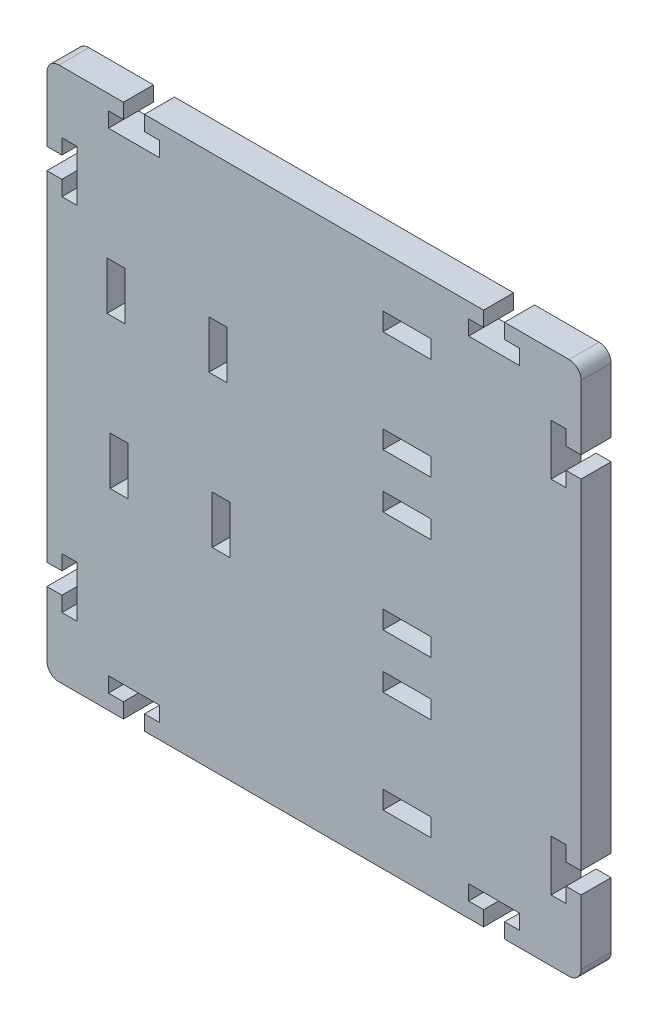
from build123d import *

# Parameters (mm, degrees)
SKETCH_1_W      = 3
SKETCH_1_H      = 8
SKETCH_1_W_2    = 8
SKETCH_1_H_2    = 3
EXTRUDE_1_DEPTH = 5


with BuildPart() as part:
    # Эскиз1 → Бобышка-Вытянуть1 (new body)
    with BuildSketch(Plane.XY):
        with BuildLine():
            Line((-31.75, 40.340066927), (-42.5, 40.340066927))
            ThreePointArc((-42.5, 40.340066927), (-43.914213562, 39.754280489), (-44.5, 38.340066927))
            Line((-44.5, 38.340066927), (-44.5, 27.590066927))
            Line((-44.5, 27.590066927), (-42, 27.590066927))
            Line((-42, 27.590066927), (-42, 30.090066927))
            Line((-42, 30.090066927), (-39.5, 30.090066927))
            Line((-39.5, 30.090066927), (-39.5, 21.590066927))
            Line((-39.5, 21.590066927), (-42, 21.590066927))
            Line((-42, 21.590066927), (-42, 24.090066927))
            Line((-42, 24.090066927), (-44.5, 24.090066927))
            Line((-44.5, 24.090066927), (-44.5, -32.409933073))
            Line((-44.5, -32.409933073), (-42, -32.409933073))
            Line((-42, -32.409933073), (-42, -29.909933073))
            Line((-42, -29.909933073), (-39.5, -29.909933073))
            Line((-39.5, -29.909933073), (-39.5, -38.409933073))
            Line((-39.5, -38.409933073), (-42, -38.409933073))
            Line((-42, -38.409933073), (-42, -35.909933073))
            Line((-42, -35.909933073), (-44.5, -35.909933073))
            Line((-44.5, -35.909933073), (-44.5, -46.659933073))
            ThreePointArc((-44.5, -46.659933073), (-43.914213562, -48.074146635), (-42.5, -48.659933073))
            Line((-42.5, -48.659933073), (-31.75, -48.659933073))
            Line((-31.75, -48.659933073), (-31.75, -46.159933073))
            Line((-31.75, -46.159933073), (-34.25, -46.159933073))
            Line((-34.25, -46.159933073), (-34.25, -43.659933073))
            Line((-34.25, -43.659933073), (-25.75, -43.659933073))
            Line((-25.75, -43.659933073), (-25.75, -46.159933073))
            Line((-25.75, -46.159933073), (-28.25, -46.159933073))
            Line((-28.25, -46.159933073), (-28.25, -48.659933073))
            Line((-28.25, -48.659933073), (28.25, -48.659933073))
            Line((28.25, -48.659933073), (28.25, -46.159933073))
            Line((28.25, -46.159933073), (25.75, -46.159933073))
            Line((25.75, -46.159933073), (25.75, -43.659933073))
            Line((25.75, -43.659933073), (34.25, -43.659933073))
            Line((34.25, -43.659933073), (34.25, -46.159933073))
            Line((34.25, -46.159933073), (31.75, -46.159933073))
            Line((31.75, -46.159933073), (31.75, -48.659933073))
            Line((31.75, -48.659933073), (42.5, -48.659933073))
            ThreePointArc((42.5, -48.659933073), (43.914213562, -48.074146635), (44.5, -46.659933073))
            Line((44.5, -46.659933073), (44.5, -35.909933073))
            Line((44.5, -35.909933073), (42, -35.909933073))
            Line((42, -35.909933073), (42, -38.409933073))
            Line((42, -38.409933073), (39.5, -38.409933073))
            Line((39.5, -38.409933073), (39.5, -29.909933073))
            Line((39.5, -29.909933073), (42, -29.909933073))
            Line((42, -29.909933073), (42, -32.409933073))
            Line((42, -32.409933073), (44.5, -32.409933073))
            Line((44.5, -32.409933073), (44.5, 24.090066927))
            Line((44.5, 24.090066927), (42, 24.090066927))
            Line((42, 24.090066927), (42, 21.590066927))
            Line((42, 21.590066927), (39.5, 21.590066927))
            Line((39.5, 21.590066927), (39.5, 30.090066927))
            Line((39.5, 30.090066927), (42, 30.090066927))
            Line((42, 30.090066927), (42, 27.590066927))
            Line((42, 27.590066927), (44.5, 27.590066927))
            Line((44.5, 27.590066927), (44.5, 38.340066927))
            ThreePointArc((44.5, 38.340066927), (43.914213562, 39.754280489), (42.5, 40.340066927))
            Line((42.5, 40.340066927), (31.75, 40.340066927))
            Line((31.75, 40.340066927), (31.75, 37.840066927))
            Line((31.75, 37.840066927), (34.25, 37.840066927))
            Line((34.25, 37.840066927), (34.25, 35.340066927))
            Line((34.25, 35.340066927), (25.75, 35.340066927))
            Line((25.75, 35.340066927), (25.75, 37.840066927))
            Line((25.75, 37.840066927), (28.25, 37.840066927))
            Line((28.25, 37.840066927), (28.25, 40.340066927))
            Line((28.25, 40.340066927), (-28.25, 40.340066927))
            Line((-28.25, 40.340066927), (-28.25, 37.840066927))
            Line((-28.25, 37.840066927), (-25.75, 37.840066927))
            Line((-25.75, 37.840066927), (-25.75, 35.340066927))
            Line((-25.75, 35.340066927), (-34.25, 35.340066927))
            Line((-34.25, 35.340066927), (-34.25, 37.840066927))
            Line((-34.25, 37.840066927), (-31.75, 37.840066927))
            Line((-31.75, 37.840066927), (-31.75, 40.340066927))
        make_face()
        with Locations((-33, 12.5)):
            Rectangle(SKETCH_1_W, SKETCH_1_H, mode=Mode.SUBTRACT)
        with Locations((-32.461916363, -12.5)):
            Rectangle(SKETCH_1_W, SKETCH_1_H, mode=Mode.SUBTRACT)
        with Locations((-16, 12.5)):
            Rectangle(SKETCH_1_W, SKETCH_1_H, mode=Mode.SUBTRACT)
        with Locations((-15.461916363, -12.5)):
            Rectangle(SKETCH_1_W, SKETCH_1_H, mode=Mode.SUBTRACT)
        with Locations((15.5, 13.340066927)):
            Rectangle(SKETCH_1_W_2, SKETCH_1_H_2, mode=Mode.SUBTRACT)
        with Locations((15.5, 30.340066927)):
            Rectangle(SKETCH_1_W_2, SKETCH_1_H_2, mode=Mode.SUBTRACT)
        with Locations((15.5, -12.659933073)):
            Rectangle(SKETCH_1_W_2, SKETCH_1_H_2, mode=Mode.SUBTRACT)
        with Locations((15.5, 4.340066927)):
            Rectangle(SKETCH_1_W_2, SKETCH_1_H_2, mode=Mode.SUBTRACT)
        with Locations((15.5, -38.659933073)):
            Rectangle(SKETCH_1_W_2, SKETCH_1_H_2, mode=Mode.SUBTRACT)
        with Locations((15.5, -21.659933073)):
            Rectangle(SKETCH_1_W_2, SKETCH_1_H_2, mode=Mode.SUBTRACT)
    extrude(amount=EXTRUDE_1_DEPTH)


solid = part.part
